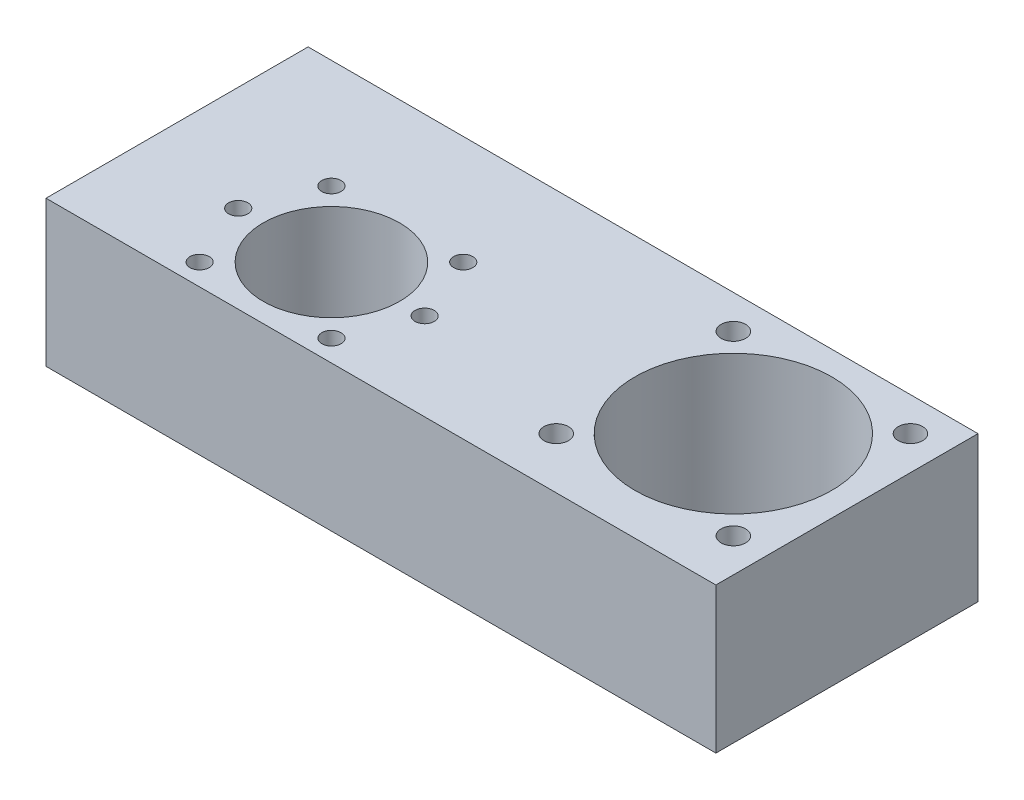
from build123d import *

# Parameters (mm, degrees)
SKETCH1_W             = 115
SKETCH1_H             = 45
BOSS_EXTRUDE1_DEPTH   = 25
SKETCH2_R             = 11.7
SKETCH2_R_2           = 16.9
CUT_EXTRUDE1_DEPTH    = 26
M5X0_8_TAPPED_HOLE1_D = 4.2
M4X0_7_TAPPED_HOLE1_D = 3.3


with BuildPart() as part:
    # Sketch1 → Boss-Extrude1 (new body)
    with BuildSketch(Plane(origin=(0, 0, 0), x_dir=(1, 0, 0), z_dir=(0, 1, 0))):
        with Locations((-57.5, 22.5)):
            Rectangle(SKETCH1_W, SKETCH1_H)
    extrude(amount=BOSS_EXTRUDE1_DEPTH)

    # Sketch2 → Cut-Extrude1 (cut, through all)
    with BuildSketch(Plane.XZ):
        with Locations((-81, -15)):
            Circle(SKETCH2_R)
        with Locations((-21, -24)):
            Circle(SKETCH2_R_2)
    extrude(amount=-CUT_EXTRUDE1_DEPTH, mode=Mode.SUBTRACT)

    # M5x0.8 Tapped Hole1 (through all)
    with Locations(Plane(origin=(0, 0, 0), x_dir=(-1, 0, 0), z_dir=(0, -1, 0))):
        with Locations((36.202795796, 39.202795796), (5.797204204, 39.202795796), (5.797204204, 8.797204204), (36.202795796, 8.797204204)):
            Hole(M5X0_8_TAPPED_HOLE1_D / 2)

    # M4x0.7 Tapped Hole1 (through all)
    with Locations(Plane(origin=(0, 0, 0), x_dir=(-1, 0, 0), z_dir=(0, -1, 0))):
        with Locations((92.313708499, 3.686291501), (97, 15), (92.313708499, 26.313708499), (69.686291501, 26.313708499), (65, 15), (69.686291501, 3.686291501)):
            Hole(M4X0_7_TAPPED_HOLE1_D / 2)


solid = part.part
